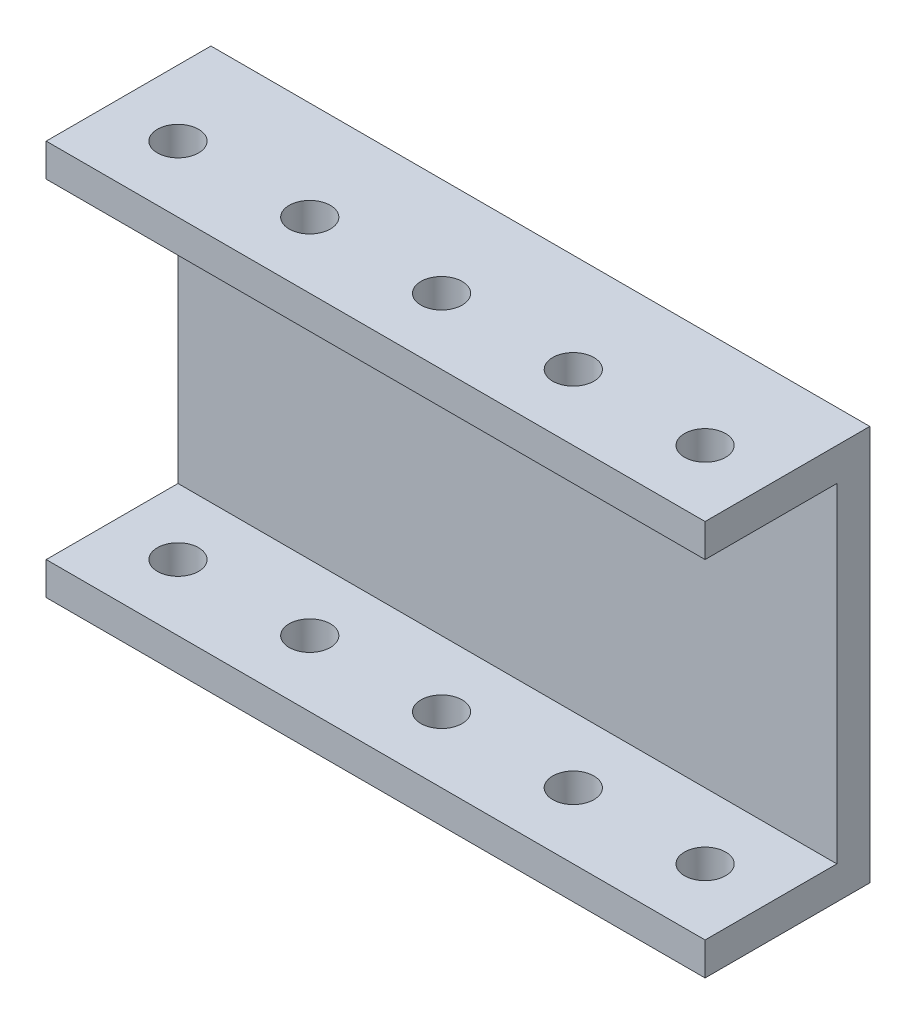
from build123d import *

# Parameters (mm, degrees)
SKETCH1_W           = 25.4
SKETCH1_H           = 6.35
BOSS_EXTRUDE1_DEPTH = 127
SKETCH2_R           = 3.96875
CUT_EXTRUDE1_DEPTH  = 77.2


with BuildPart() as part:
    # Sketch1 → Boss-Extrude1 (new body)
    with BuildSketch(Plane(origin=(0, 0, 0), x_dir=(0, 0, -1), z_dir=(1, 0, 0))):
        with Locations((9.890468116, 35.572429457)):
            Rectangle(SKETCH1_W, SKETCH1_H)
        Polygon((28.940468116, 38.747429457), (22.590468116, 38.747429457), (22.590468116, 32.397429457), (22.590468116, -31.102570543), (22.590468116, -37.452570543), (28.940468116, -37.452570543), align=None)
        with Locations((9.890468116, -34.277570543)):
            Rectangle(SKETCH1_W, SKETCH1_H)
    extrude(amount=BOSS_EXTRUDE1_DEPTH)

    # Sketch2 → Cut-Extrude1 (cut, through all)
    with BuildSketch(Plane(origin=(0, 38.747429457, 0), x_dir=(1, 0, 0), z_dir=(0, 1, 0))):
        with Locations((114.3, 9.890468116)):
            Circle(SKETCH2_R)
        with Locations((88.9, 9.890468116)):
            Circle(SKETCH2_R)
        with Locations((63.5, 9.890468116)):
            Circle(SKETCH2_R)
        with Locations((38.1, 9.890468116)):
            Circle(SKETCH2_R)
        with Locations((12.7, 9.890468116)):
            Circle(SKETCH2_R)
    extrude(amount=-CUT_EXTRUDE1_DEPTH, mode=Mode.SUBTRACT)


solid = part.part
